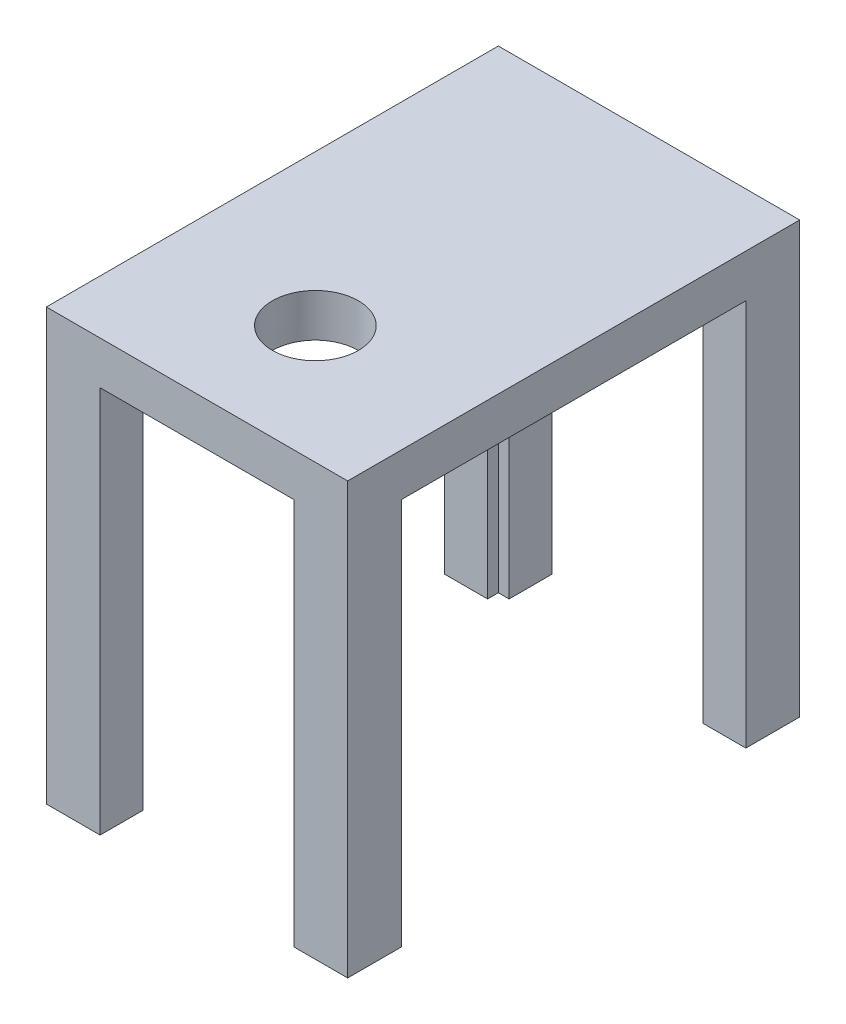
from build123d import *

# Parameters (mm, degrees)
SKETCH1_W               = 71.12
SKETCH1_H               = 106.68
BOSS_EXTRUDE1_DEPTH     = 101.6
SHELL1_T                = -10.16
SKETCH3_R               = 1.5875
CUT_EXTRUDE1_DEPTH      = 10.16
SKETCH4_W               = 81.28
SKETCH4_H               = 91.44
CUT_EXTRUDE2_DEPTH      = 72.12
CUT_EXTRUDE3_DEPTH      = 3.175
SKETCH7_W               = 45.72
SKETCH7_H               = 91.44
CUT_EXTRUDE4_DEPTH      = 1
CUT_EXTRUDE4_DEPTH_BACK = 107.68
CUT_EXTRUDE5_REACH      = 103.6
SKETCH8_R               = 10.16


with BuildPart() as part:
    # Sketch1 → Boss-Extrude1 (new body)
    with BuildSketch(Plane(origin=(0, 0, 0), x_dir=(1, 0, 0), z_dir=(0, 1, 0))):
        with Locations((35.56, 53.34)):
            Rectangle(SKETCH1_W, SKETCH1_H)
    extrude(amount=BOSS_EXTRUDE1_DEPTH)

    # Shell1
    shell1_openings = [part.faces().sort_by_distance(p)[0] for p in [
        (35.56, 0, -53.34),
    ]]
    offset(amount=SHELL1_T, openings=shell1_openings, kind=Kind.INTERSECTION)

    # Sketch3 → Cut-Extrude1 (cut)
    with BuildSketch(Plane.XZ):
        with Locations((6.35, -6.35)):
            Circle(SKETCH3_R)
        with Locations((64.77, -6.35)):
            Circle(SKETCH3_R)
        with Locations((64.77, -100.33)):
            Circle(SKETCH3_R)
        with Locations((6.35, -100.33)):
            Circle(SKETCH3_R)
    extrude(amount=-CUT_EXTRUDE1_DEPTH, mode=Mode.SUBTRACT)

    # Sketch4 → Cut-Extrude2 (cut, through all)
    with BuildSketch(Plane.ZY):
        with Locations((-53.34, 45.72)):
            Rectangle(SKETCH4_W, SKETCH4_H)
    extrude(amount=-CUT_EXTRUDE2_DEPTH, mode=Mode.SUBTRACT)

    # Sketch6 → Cut-Extrude3 (cut)
    with BuildSketch(Plane.XZ):
        Polygon((69.536026472, -6.35), (67.153013236, -2.2225), (62.386986764, -2.2225), (60.003973528, -6.35), (62.386986764, -10.4775), (67.153013236, -10.4775), align=None)
        Polygon((11.116026472, -6.35), (8.733013236, -2.2225), (3.966986764, -2.2225), (1.583973528, -6.35), (3.966986764, -10.4775), (8.733013236, -10.4775), align=None)
        Polygon((69.536026472, -100.33), (67.153013236, -96.2025), (62.386986764, -96.2025), (60.003973528, -100.33), (62.386986764, -104.4575), (67.153013236, -104.4575), align=None)
        Polygon((11.116026472, -100.33), (8.733013236, -96.2025), (3.966986764, -96.2025), (1.583973528, -100.33), (3.966986764, -104.4575), (8.733013236, -104.4575), align=None)
    extrude(amount=-CUT_EXTRUDE3_DEPTH, mode=Mode.SUBTRACT)

    # Sketch7 → Cut-Extrude4 (cut, two sides)
    with BuildSketch(Plane(origin=(0, 0, -106.68), x_dir=(-1, 0, 0), z_dir=(0, 0, -1))) as cut_extrude4_sk:
        with Locations((-35.56, 45.72)):
            Rectangle(SKETCH7_W, SKETCH7_H)
    extrude(amount=CUT_EXTRUDE4_DEPTH, mode=Mode.SUBTRACT)
    extrude(cut_extrude4_sk.sketch, amount=-CUT_EXTRUDE4_DEPTH_BACK, mode=Mode.SUBTRACT)

    # Sketch8 → Cut-Extrude5 (cut, up to next)
    with BuildSketch(Plane(origin=(0, 101.6, 0), x_dir=(1, 0, 0), z_dir=(0, 1, 0)), mode=Mode.PRIVATE) as cut_extrude5_sk1:
        with Locations((35.56, 27.94)):
            Circle(SKETCH8_R)
    cut_extrude5_tool1 = extrude(cut_extrude5_sk1.sketch, amount=-CUT_EXTRUDE5_REACH, mode=Mode.PRIVATE) & part.part
    add(cut_extrude5_tool1.solids().sort_by_distance((35.56, 101.6, -27.94))[0], mode=Mode.SUBTRACT)


solid = part.part
